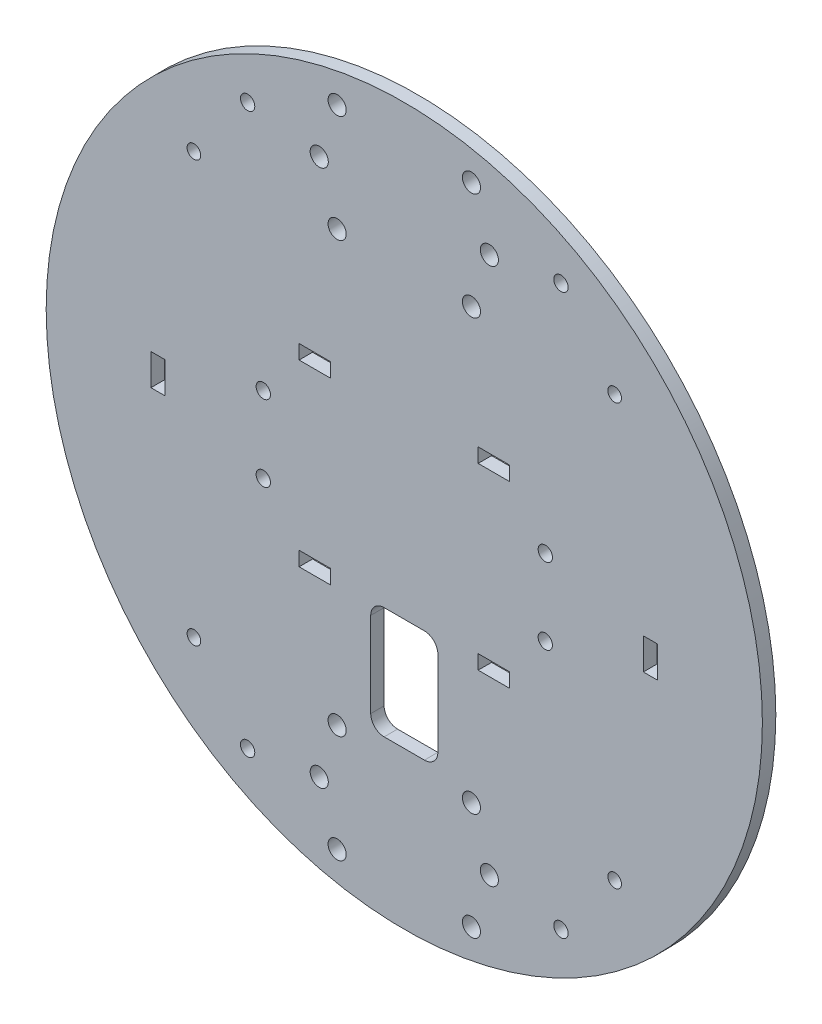
from build123d import *

# Parameters (mm, degrees)
SKETCH_1_R      = 80
SKETCH_1_R_2    = 1.52
SKETCH_1_R_3    = 2.025
SKETCH_1_R_4    = 1.6
SKETCH_1_W      = 15
SKETCH_1_H      = 25
EXTRUDE_1_DEPTH = 3
SKETCH_1103_W   = 7
SKETCH_1103_H   = 3.2
SKETCH_1103_W_2 = 3.2
SKETCH_1103_H_2 = 7
BB_DEPTH        = 3
FILLET_1_R      = 3


with BuildPart() as part:
    # 草图1 → 凸台-拉伸1 (new body)
    with BuildSketch(Plane.XY):
        Circle(SKETCH_1_R)
        with Locations((-47, 47)):
            Circle(SKETCH_1_R_2, mode=Mode.SUBTRACT)
        with Locations((47, 47)):
            Circle(SKETCH_1_R_2, mode=Mode.SUBTRACT)
        with Locations((47, -47)):
            Circle(SKETCH_1_R_2, mode=Mode.SUBTRACT)
        with Locations((-47, -47)):
            Circle(SKETCH_1_R_2, mode=Mode.SUBTRACT)
        with Locations((19, 60)):
            Circle(SKETCH_1_R_3, mode=Mode.SUBTRACT)
        with Locations((15, 72)):
            Circle(SKETCH_1_R_3, mode=Mode.SUBTRACT)
        with Locations((15, 48)):
            Circle(SKETCH_1_R_3, mode=Mode.SUBTRACT)
        with Locations((-15, 48)):
            Circle(SKETCH_1_R_3, mode=Mode.SUBTRACT)
        with Locations((-19, 60)):
            Circle(SKETCH_1_R_3, mode=Mode.SUBTRACT)
        with Locations((-15, 72)):
            Circle(SKETCH_1_R_3, mode=Mode.SUBTRACT)
        with Locations((15, -48)):
            Circle(SKETCH_1_R_3, mode=Mode.SUBTRACT)
        with Locations((15, -72)):
            Circle(SKETCH_1_R_3, mode=Mode.SUBTRACT)
        with Locations((19, -60)):
            Circle(SKETCH_1_R_3, mode=Mode.SUBTRACT)
        with Locations((-15, -48)):
            Circle(SKETCH_1_R_3, mode=Mode.SUBTRACT)
        with Locations((-19, -60)):
            Circle(SKETCH_1_R_3, mode=Mode.SUBTRACT)
        with Locations((-15, -72)):
            Circle(SKETCH_1_R_3, mode=Mode.SUBTRACT)
        with Locations((-35, 62.5)):
            Circle(SKETCH_1_R_4, mode=Mode.SUBTRACT)
        with Locations((-35, -62.5)):
            Circle(SKETCH_1_R_4, mode=Mode.SUBTRACT)
        with Locations((-31.5, 8.5)):
            Circle(SKETCH_1_R_4, mode=Mode.SUBTRACT)
        with Locations((-31.5, -8.5)):
            Circle(SKETCH_1_R_4, mode=Mode.SUBTRACT)
        with Locations((31.5, -8.5)):
            Circle(SKETCH_1_R_4, mode=Mode.SUBTRACT)
        with Locations((31.5, 8.5)):
            Circle(SKETCH_1_R_4, mode=Mode.SUBTRACT)
        with Locations((35, 62.5)):
            Circle(SKETCH_1_R_4, mode=Mode.SUBTRACT)
        with Locations((35, -62.5)):
            Circle(SKETCH_1_R_4, mode=Mode.SUBTRACT)
        with Locations((0, -32.5)):
            Rectangle(SKETCH_1_W, SKETCH_1_H, mode=Mode.SUBTRACT)
    extrude(amount=EXTRUDE_1_DEPTH)

    # Sketch 1103 → 电池+BB响扎带孔位 (cut)
    with BuildSketch(Plane.XY):
        with Locations((20, -20)):
            Rectangle(SKETCH_1103_W, SKETCH_1103_H)
        with Locations((20, 20)):
            Rectangle(SKETCH_1103_W, SKETCH_1103_H)
        with Locations((55, 0)):
            Rectangle(SKETCH_1103_W_2, SKETCH_1103_H_2)
        with Locations((-20, 20)):
            Rectangle(SKETCH_1103_W, SKETCH_1103_H)
        with Locations((-55, 0)):
            Rectangle(SKETCH_1103_W_2, SKETCH_1103_H_2)
        with Locations((-20, -20)):
            Rectangle(SKETCH_1103_W, SKETCH_1103_H)
    extrude(amount=BB_DEPTH, mode=Mode.SUBTRACT)

    # 圆角1
    fillet_1_edges = [part.edges().sort_by_distance(p)[0] for p in [
        (-7.5, -20, 1.5),
        (-7.5, -45, 1.5),
        (7.5, -45, 1.5),
        (7.5, -20, 1.5),
    ]]
    fillet(fillet_1_edges, radius=FILLET_1_R)


solid = part.part
